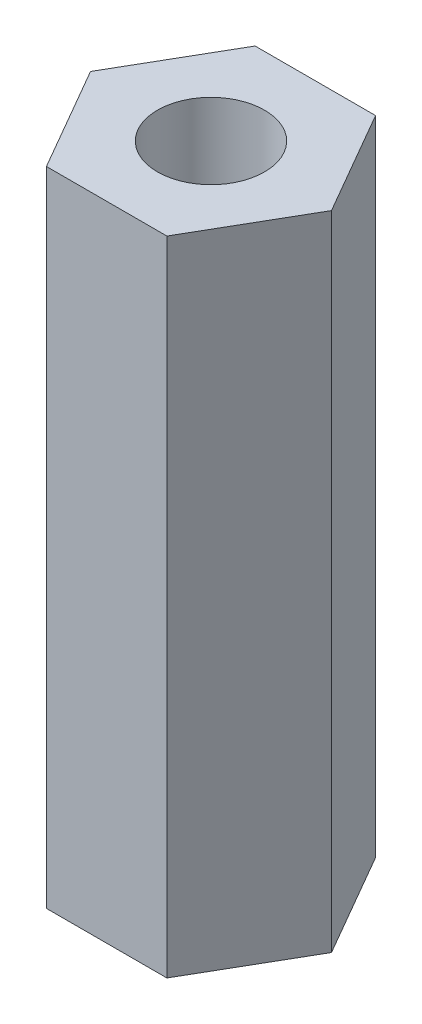
from build123d import *

# Parameters (mm, degrees)
SKETCH1_R           = 1
BOSS_EXTRUDE1_DEPTH = 12


with BuildPart() as part:
    # Sketch1 → Boss-Extrude1 (new body)
    with BuildSketch(Plane(origin=(0, 0, 0), x_dir=(1, 0, 0), z_dir=(0, 1, 0))):
        Polygon((2.25, 0), (1.125, 1.948557159), (-1.125, 1.948557159), (-2.25, 0), (-1.125, -1.948557159), (1.125, -1.948557159), align=None)
        Circle(SKETCH1_R, mode=Mode.SUBTRACT)
    extrude(amount=BOSS_EXTRUDE1_DEPTH)


solid = part.part
